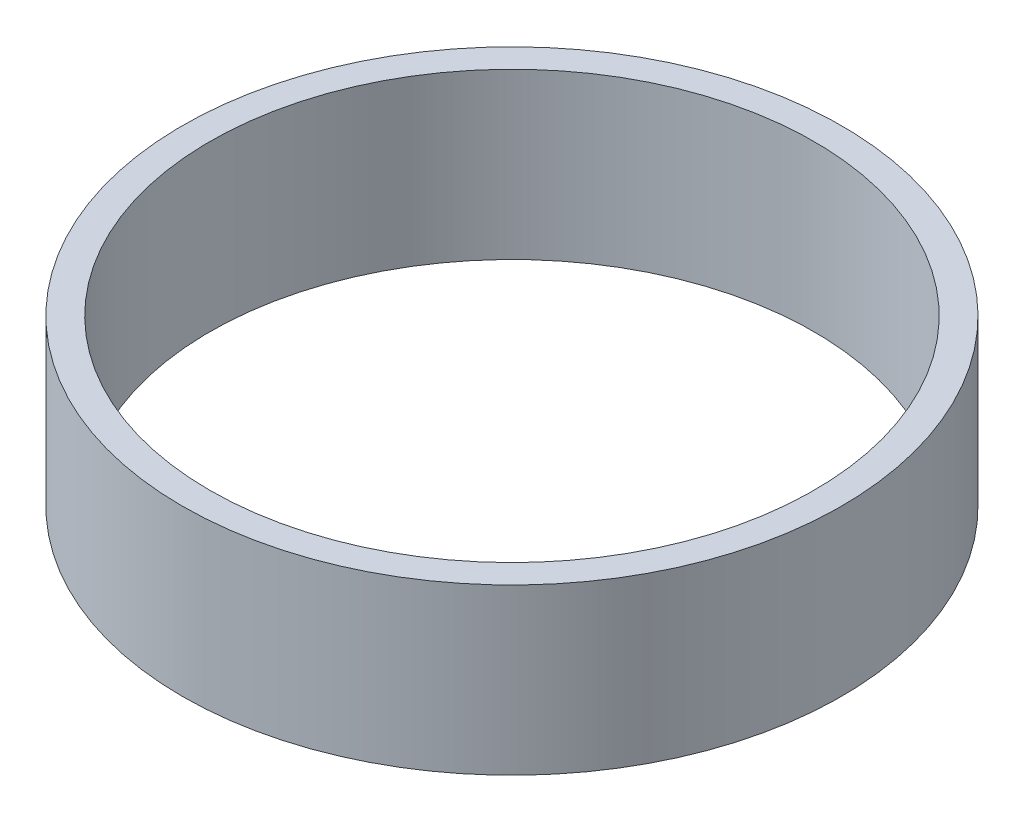
from build123d import *

# Parameters (mm, degrees)
SKETCH_1_R      = 60
EXTRUDE_1_DEPTH = 30
SHELL_1_T       = -5


with BuildPart() as part:
    # 草圖1 → 填料-伸長1 (new body)
    with BuildSketch(Plane(origin=(0, 0, 0), x_dir=(1, 0, 0), z_dir=(0, 1, 0))):
        with Locations(Location((0, 0, 0), (0, 0, 270))):
            Circle(SKETCH_1_R)
    extrude(amount=EXTRUDE_1_DEPTH)

    # 薄殼1
    shell_1_openings = [part.faces().sort_by_distance(p)[0] for p in [
        (0, 30, 0),
        (0, 0, 0),
    ]]
    offset(amount=SHELL_1_T, openings=shell_1_openings, kind=Kind.INTERSECTION)


solid = part.part
